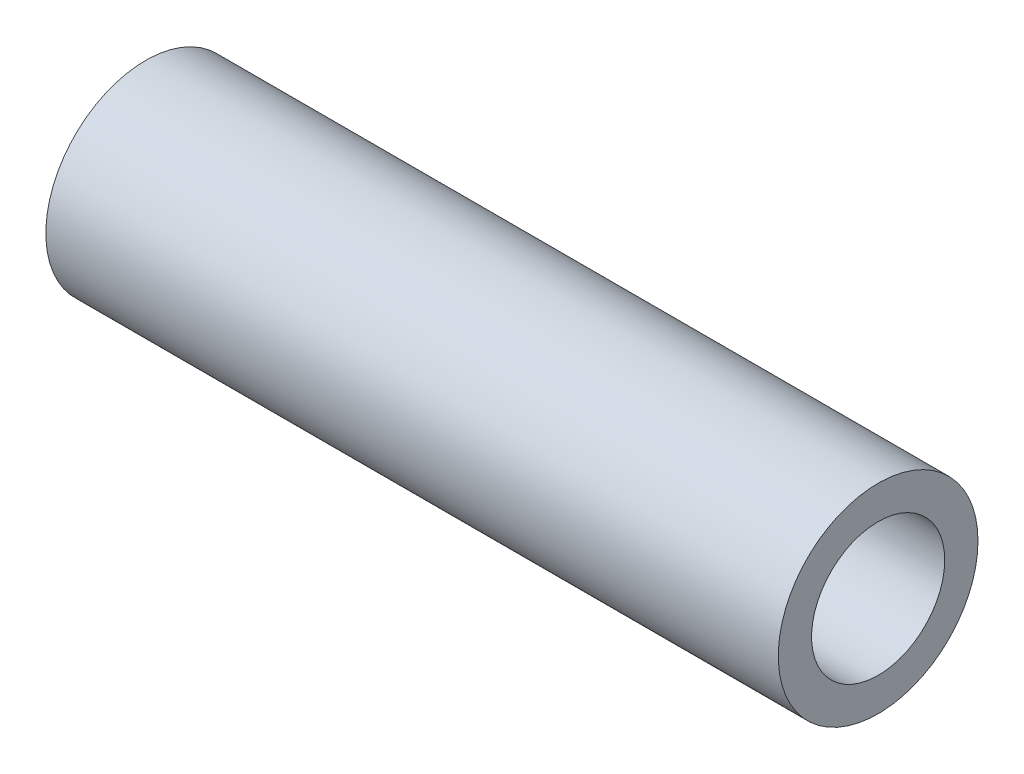
from build123d import *

# Parameters (mm, degrees)
BOSS_EXTRUDE1_DEPTH      = 25.87625
BOSS_EXTRUDE1_DEPTH_BACK = 25.87625
SKETCH1_R                = 7.05612
SKETCH1_R_2              = 4.70408


with BuildPart() as part:
    # Sketch1 → Boss-Extrude1 (new, two sides: drawn at the far end of the back side and taken through both)
    with BuildSketch(Plane(origin=(0, 0, 0), x_dir=(0, 0, -1), z_dir=(1, 0, 0)).offset(-BOSS_EXTRUDE1_DEPTH_BACK)):
        Circle(SKETCH1_R)
        Circle(SKETCH1_R_2, mode=Mode.SUBTRACT)
    extrude(amount=BOSS_EXTRUDE1_DEPTH + BOSS_EXTRUDE1_DEPTH_BACK)


solid = part.part
